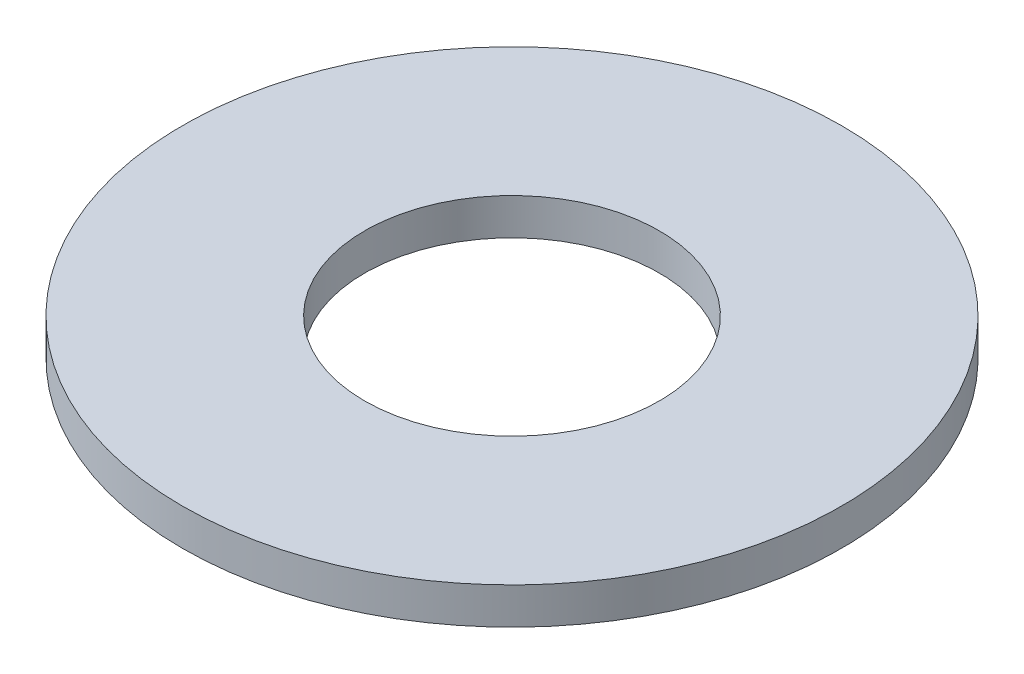
from build123d import *

# Parameters (mm, degrees)
SKETCH1_R           = 9
SKETCH1_R_2         = 4.025
BOSS_EXTRUDE1_DEPTH = 1


with BuildPart() as part:
    # Sketch1 → Boss-Extrude1 (new body)
    with BuildSketch(Plane(origin=(0, 0, 0), x_dir=(1, 0, 0), z_dir=(0, 1, 0))):
        Circle(SKETCH1_R)
        Circle(SKETCH1_R_2, mode=Mode.SUBTRACT)
    extrude(amount=BOSS_EXTRUDE1_DEPTH)


solid = part.part
